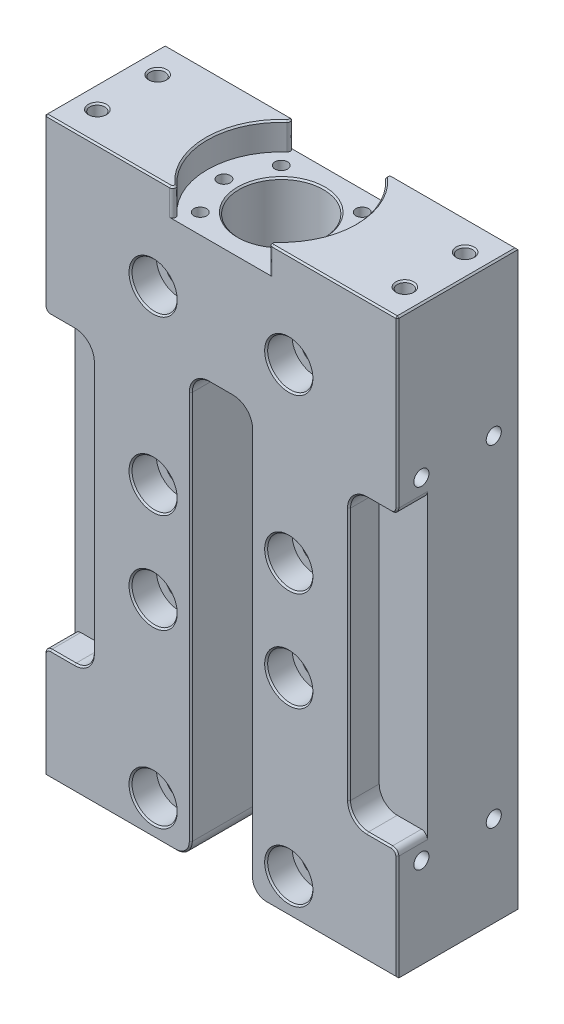
from build123d import *

# Parameters (mm, degrees)
BOSS_EXTRU_1_DEPTH                                  = 40
ESQUISSE1_4_W                                       = 16
ESQUISSE1_4_H                                       = 96
BOSS_EXTRUDE1_DEPTH                                 = 30
ESQUISSE3_R                                         = 14
ENL_V_MAT_EXTRU_2_DEPTH                             = 40
CONG_1_R                                            = 6
CBORE_FOR_M8_HEX_SOCKET_HEAD_CAP_SCREW2_D           = 9
CBORE_FOR_M8_HEX_SOCKET_HEAD_CAP_SCREW2_CBORE_D     = 15
CBORE_FOR_M8_HEX_SOCKET_HEAD_CAP_SCREW2_CBORE_DEPTH = 8.6
SKETCH7_R                                           = 24.5
CUT_EXTRUDE2_DEPTH                                  = 9
M5_TAPPED_HOLE2_D                                   = 4.2
M5_TAPPED_HOLE2_DEPTH                               = 14
M5_TAPPED_HOLE2_TIP                                 = 1.2618073
SKETCH12_R                                          = 9
CUT_EXTRUDE3_DEPTH                                  = 166.898312228
TAP_DRILL_FOR_M6_TAP2_AT_2_COUNT                    = 2
TAP_DRILL_FOR_M6_TAP2_AT_2_PITCH                    = 24
TAP_DRILL_FOR_M6_TAP2_AT_3_COUNT                    = 2
TAP_DRILL_FOR_M6_TAP2_AT_3_PITCH                    = 110
TAP_DRILL_FOR_M6_TAP2_AT_4_COUNT                    = 2
TAP_DRILL_FOR_M6_TAP2_AT_4_PITCH                    = 112.58774356
FILLET2_R                                           = 5
FILLET3_R                                           = 6
FILLET4_R                                           = 2
TAP_DRILL_FOR_M6_TAP1_D                             = 5
TAP_DRILL_FOR_M6_TAP1_DEPTH                         = 23
TAP_DRILL_FOR_M6_TAP1_TIP                           = 1.502151548
FILLET1_R                                           = 1
CHAMFER1_SIZE                                       = 0.5


with BuildPart() as part:
    # Esquisse1 → Boss.-Extru.1 (new body)
    with BuildSketch(Plane.XY):
        Polygon((-58.5, -85), (-10, -85), (-10, 55), (10, 55), (10, -85), (58.5, -85), (58.5, -48), (42.5, -48), (42.5, 48), (58.5, 48), (58.5, 105), (-58.5, 105), (-58.5, 48), (-42.5, 48), (-42.5, -48), (-58.5, -48), align=None)
    extrude(amount=BOSS_EXTRU_1_DEPTH)

    # Esquisse1_4 → Boss-Extrude1 (add)
    with BuildSketch(Plane.XY):
        with Locations((-50.5, 0)):
            Rectangle(ESQUISSE1_4_W, ESQUISSE1_4_H)
        with Locations((50.5, 0)):
            Rectangle(ESQUISSE1_4_W, ESQUISSE1_4_H)
    extrude(amount=BOSS_EXTRUDE1_DEPTH)

    # Esquisse3 → Enlèv. mat.-Extru.2 (cut)
    with BuildSketch(Plane(origin=(0, 105, 0), x_dir=(1, 0, 0), z_dir=(0, 1, 0))):
        with Locations((0, -20)):
            Circle(ESQUISSE3_R)
    extrude(amount=-ENL_V_MAT_EXTRU_2_DEPTH, mode=Mode.SUBTRACT)

    # Congé1
    cong_1_edges = [part.edges().sort_by_distance(p)[0] for p in [
        (10, 55, 20),
        (-10, 55, 20),
    ]]
    fillet(cong_1_edges, radius=CONG_1_R)

    # CBORE for M8 Hex Socket Head Cap Screw2 (through all)
    with Locations(Plane.XY.offset(40)):
        with Locations((-22.5, 73.5), (22.5, 73.5), (22.5, 16.5), (-22.5, 16.5), (-22.5, -16.5), (22.5, -16.5), (22.5, -73.5), (-22.5, -73.5)):
            CounterBoreHole(CBORE_FOR_M8_HEX_SOCKET_HEAD_CAP_SCREW2_D / 2, CBORE_FOR_M8_HEX_SOCKET_HEAD_CAP_SCREW2_CBORE_D / 2, CBORE_FOR_M8_HEX_SOCKET_HEAD_CAP_SCREW2_CBORE_DEPTH)

    # Sketch7 → Cut-Extrude2 (cut)
    with BuildSketch(Plane(origin=(0, 105, 0), x_dir=(1, 0, 0), z_dir=(0, 1, 0))):
        with Locations((0, -20)):
            Circle(SKETCH7_R)
    extrude(amount=-CUT_EXTRUDE2_DEPTH, mode=Mode.SUBTRACT)

    # M5 Tapped Hole2
    with Locations(Plane(origin=(0, 96, 0), x_dir=(1, 0, 0), z_dir=(0, 1, 0))):
        with Locations((-13.435028843, -6.564971157), (-19, -20), (13.435028843, -6.564971157), (19, -20), (13.435028843, -33.435028843), (-13.435028843, -33.435028843)):
            Hole(M5_TAPPED_HOLE2_D / 2, depth=M5_TAPPED_HOLE2_DEPTH)
            with Locations((0, 0, -(M5_TAPPED_HOLE2_DEPTH + M5_TAPPED_HOLE2_TIP / 2))):  # 118° drill point
                Cone(0, M5_TAPPED_HOLE2_D / 2, M5_TAPPED_HOLE2_TIP, mode=Mode.SUBTRACT)

    # Sketch12 → Cut-Extrude3 (cut, through all)
    with BuildSketch(Plane(origin=(0, 65, 0), x_dir=(1, 0, 0), z_dir=(0, 1, 0))):
        with Locations((0, -20)):
            Circle(SKETCH12_R)
    extrude(amount=-CUT_EXTRUDE3_DEPTH, mode=Mode.SUBTRACT)

    # Sketch14 → Tap Drill for M6 Tap2 (revolve, cut)
    with BuildSketch(Plane(origin=(58.5, 55, 8), x_dir=(0, 0, -1), z_dir=(0, 1, 0))):
        Polygon((0, 0), (0, 11.502151548), (2.5, 10), (2.5, 0), align=None)
    tap_drill_for_m6_tap2 = revolve(axis=Axis((64.85, 55, 8), (-1, 0, 0)), mode=Mode.SUBTRACT)

    # Tap Drill for M6 Tap2 at 2: Tap Drill for M6 Tap2 ×2
    with Locations(*[(0, 0, i * TAP_DRILL_FOR_M6_TAP2_AT_2_PITCH) for i in range(1, TAP_DRILL_FOR_M6_TAP2_AT_2_COUNT)]):
        add(tap_drill_for_m6_tap2, mode=Mode.SUBTRACT)

    # Tap Drill for M6 Tap2 at 3: Tap Drill for M6 Tap2 ×2
    with Locations(*[(0, -i * TAP_DRILL_FOR_M6_TAP2_AT_3_PITCH, 0) for i in range(1, TAP_DRILL_FOR_M6_TAP2_AT_3_COUNT)]):
        add(tap_drill_for_m6_tap2, mode=Mode.SUBTRACT)

    # Tap Drill for M6 Tap2 at 4: Tap Drill for M6 Tap2 ×2
    with Locations(*[Vector(0, -0.9770157614099922, 0.21316707521672548) * (i * TAP_DRILL_FOR_M6_TAP2_AT_4_PITCH) for i in range(1, TAP_DRILL_FOR_M6_TAP2_AT_4_COUNT)]):
        add(tap_drill_for_m6_tap2, mode=Mode.SUBTRACT)

    # Mirror1: Tap Drill for M6 Tap2 across plane
    add(tap_drill_for_m6_tap2.mirror(Plane(origin=(0, 0, 0), x_dir=(0, 0, 1), z_dir=(1, 0, 0))), mode=Mode.SUBTRACT)

    # Mirror1 copy 1 sketch → Mirror1 copy 1 (revolve, cut)
    with BuildSketch(Plane(origin=(-58.5, 55, 32), x_dir=(0, 0, -1), z_dir=(0, 1, 0))):
        Polygon((0, 0), (0, -11.502151548), (2.5, -10), (2.5, 0), align=None)
    revolve(axis=Axis((-64.85, 55, 32), (-1, 0, 0)), mode=Mode.SUBTRACT)

    # Mirror1 copy 2 sketch → Mirror1 copy 2 (revolve, cut)
    with BuildSketch(Plane(origin=(-58.5, -55, 8), x_dir=(0, 0, -1), z_dir=(0, 1, 0))):
        Polygon((0, 0), (0, -11.502151548), (2.5, -10), (2.5, 0), align=None)
    revolve(axis=Axis((-64.85, -55, 8), (-1, 0, 0)), mode=Mode.SUBTRACT)

    # Mirror1 copy 3 sketch → Mirror1 copy 3 (revolve, cut)
    with BuildSketch(Plane(origin=(-58.5, -55, 32), x_dir=(0, 0, -1), z_dir=(0, 1, 0))):
        Polygon((0, 0), (0, -11.502151548), (2.5, -10), (2.5, 0), align=None)
    revolve(axis=Axis((-64.85, -55, 32), (-1, 0, 0)), mode=Mode.SUBTRACT)

    # Fillet2
    fillet2_edges = [part.edges().sort_by_distance(p)[0] for p in [
        (10, -85, 20),
        (-10, -85, 20),
    ]]
    fillet(fillet2_edges, radius=FILLET2_R)

    # Fillet3
    fillet3_edges = [part.edges().sort_by_distance(p)[0] for p in [
        (-42.5, 48, 35),
        (-42.5, -48, 35),
        (42.5, -48, 35),
        (42.5, 48, 35),
    ]]
    fillet(fillet3_edges, radius=FILLET3_R)

    # Fillet4
    fillet4_edges = [part.edges().sort_by_distance(p)[0] for p in [
        (58.5, -48, 35),
        (58.5, 48, 35),
        (-58.5, -48, 35),
        (-58.5, 48, 35),
    ]]
    fillet(fillet4_edges, radius=FILLET4_R)

    # Tap Drill for M6 Tap1
    with Locations(Plane(origin=(0, 105, 0), x_dir=(1, 0, 0), z_dir=(0, 1, 0))):
        with Locations((-51, -30), (-51, -10), (51, -10), (51, -30)):
            Hole(TAP_DRILL_FOR_M6_TAP1_D / 2, depth=TAP_DRILL_FOR_M6_TAP1_DEPTH)
            with Locations((0, 0, -(TAP_DRILL_FOR_M6_TAP1_DEPTH + TAP_DRILL_FOR_M6_TAP1_TIP / 2))):  # 118° drill point
                Cone(0, TAP_DRILL_FOR_M6_TAP1_D / 2, TAP_DRILL_FOR_M6_TAP1_TIP, mode=Mode.SUBTRACT)

    # Fillet1
    fillet1_edges = [part.edges().sort_by_distance(p)[0] for p in [
        (14.150971698, 100.5, 40),
        (-14.150971698, 100.5, 40),
        (-14.150971698, 100.5, 0),
        (14.150971698, 100.5, 0),
    ]]
    fillet(fillet1_edges, radius=FILLET1_R)

    # Chamfer1
    chamfer1_edges = [part.edges().sort_by_distance(p)[0] for p in [
        (-36.75, -85, 40),
        (-11.464466094, -83.535533906, 40),
        (-10, -15.5, 40),
        (-8.242640687, 53.242640687, 40),
        (0, 55, 40),
        (8.242640687, 53.242640687, 40),
        (10, -15.5, 40),
        (11.464466094, -83.535533906, 40),
        (36.75, -85, 40),
        (58.5, -67.5, 40),
        (58.5, 77.5, 40),
        (57.914213562, -48.585786438, 40),
        (57.914213562, 48.585786438, 40),
        (52.5, -48, 40),
        (52.5, 48, 40),
        (44.257359313, -46.242640687, 40),
        (44.257359313, 46.242640687, 40),
        (42.5, 0, 40),
        (-58.5, 77.5, 40),
        (-58.5, -67.5, 40),
        (-57.914213562, 48.585786438, 40),
        (-57.914213562, -48.585786438, 40),
        (-52.5, 48, 40),
        (-52.5, -48, 40),
        (-44.257359313, 46.242640687, 40),
        (-44.257359313, -46.242640687, 40),
        (-42.5, 0, 40),
        (-37.753675676, 105, 40),
        (37.753675676, 105, 40),
        (-37.753675676, 105, 0),
        (-16.073248028, 105, 0.642997226),
        (-24.5, 105, 20),
        (-16.073248028, 105, 39.357002774),
        (37.753675676, 105, 0),
        (16.073248028, 105, 0.642997226),
        (24.5, 105, 20),
        (16.073248028, 105, 39.357002774),
        (-14, 96, 20),
        (53.5, 105, 30),
        (53.5, 105, 10),
        (-48.5, 105, 30),
        (-48.5, 105, 10),
        (-58.5, 105, 20),
        (58.5, 105, 20),
        (-30, -73.5, 40),
        (15, -73.5, 40),
        (15, -16.5, 40),
        (15, 16.5, 40),
        (-30, -16.5, 40),
        (-30, 16.5, 40),
        (-30, 73.5, 40),
        (15, 73.5, 40),
    ]]
    chamfer(chamfer1_edges, length=CHAMFER1_SIZE)


solid = part.part
